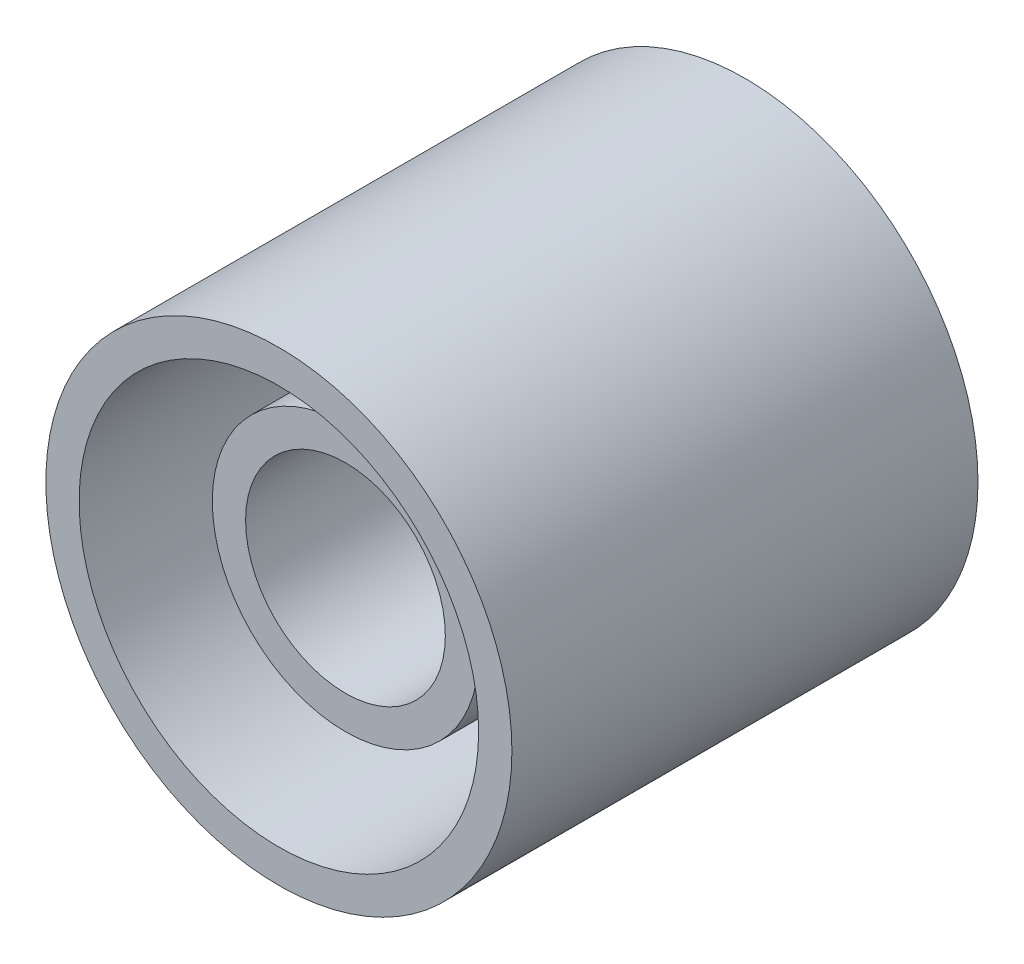
from build123d import *

# Parameters (mm, degrees)
SKETCH3_R           = 1.75
BOSS_EXTRUDE1_DEPTH = 3.5
SKETCH4_R           = 0.75
CUT_EXTRUDE1_DEPTH  = 3
SKETCH6_R           = 1.5
SKETCH6_R_2         = 1
CUT_EXTRUDE6_DEPTH  = 3
SKETCH10_R          = 1
CUT_EXTRUDE7_DEPTH  = 0.5
SKETCH12_R          = 1.5
CUT_EXTRUDE8_DEPTH  = 0.3


with BuildPart() as part:
    # Sketch3 → Boss-Extrude1 (new body)
    with BuildSketch(Plane.XY):
        Circle(SKETCH3_R)
    extrude(amount=BOSS_EXTRUDE1_DEPTH)

    # Sketch4 → Cut-Extrude1 (cut)
    with BuildSketch(Plane.XY.offset(3.5)):
        Circle(SKETCH4_R)
    extrude(amount=-CUT_EXTRUDE1_DEPTH, mode=Mode.SUBTRACT)

    # Sketch6 → Cut-Extrude6 (cut)
    with BuildSketch(Plane.XY.offset(3.5)):
        Circle(SKETCH6_R)
        Circle(SKETCH6_R_2, mode=Mode.SUBTRACT)
    extrude(amount=-CUT_EXTRUDE6_DEPTH, mode=Mode.SUBTRACT)

    # Sketch10 → Cut-Extrude7 (cut)
    with BuildSketch(Plane.XY.offset(3.5)):
        Circle(SKETCH10_R)
    extrude(amount=-CUT_EXTRUDE7_DEPTH, mode=Mode.SUBTRACT)

    # Sketch12 → Cut-Extrude8 (cut)
    with BuildSketch(Plane(origin=(0, 0, 0), x_dir=(-1, 0, 0), z_dir=(0, 0, -1))):
        Circle(SKETCH12_R)
    extrude(amount=-CUT_EXTRUDE8_DEPTH, mode=Mode.SUBTRACT)


solid = part.part
